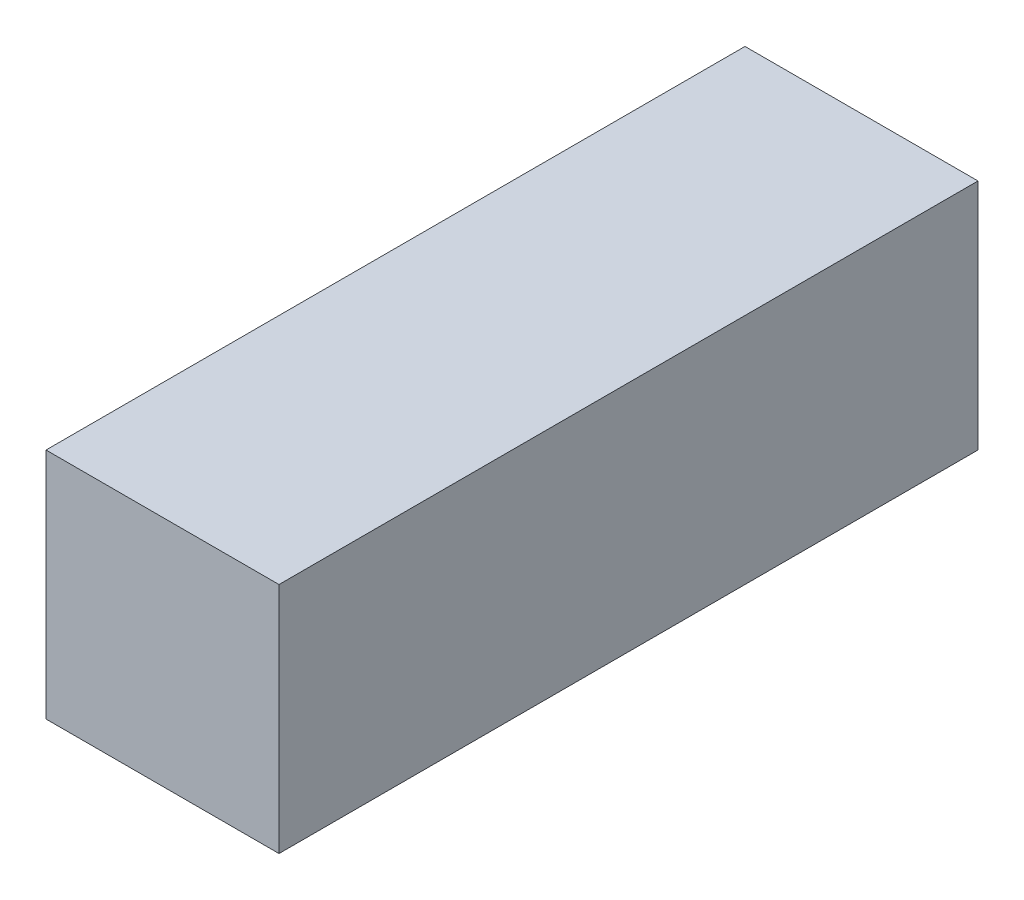
from build123d import *

# Parameters (mm, degrees)
SKETCH1_W           = 101.6
SKETCH1_H           = 304.8
BOSS_EXTRUDE1_DEPTH = 101.6


with BuildPart() as part:
    # Sketch1 → Boss-Extrude1 (new body)
    with BuildSketch(Plane(origin=(0, 0, 0), x_dir=(1, 0, 0), z_dir=(0, 1, 0))):
        with Locations((50.8, 152.4)):
            Rectangle(SKETCH1_W, SKETCH1_H)
    extrude(amount=BOSS_EXTRUDE1_DEPTH)


solid = part.part
